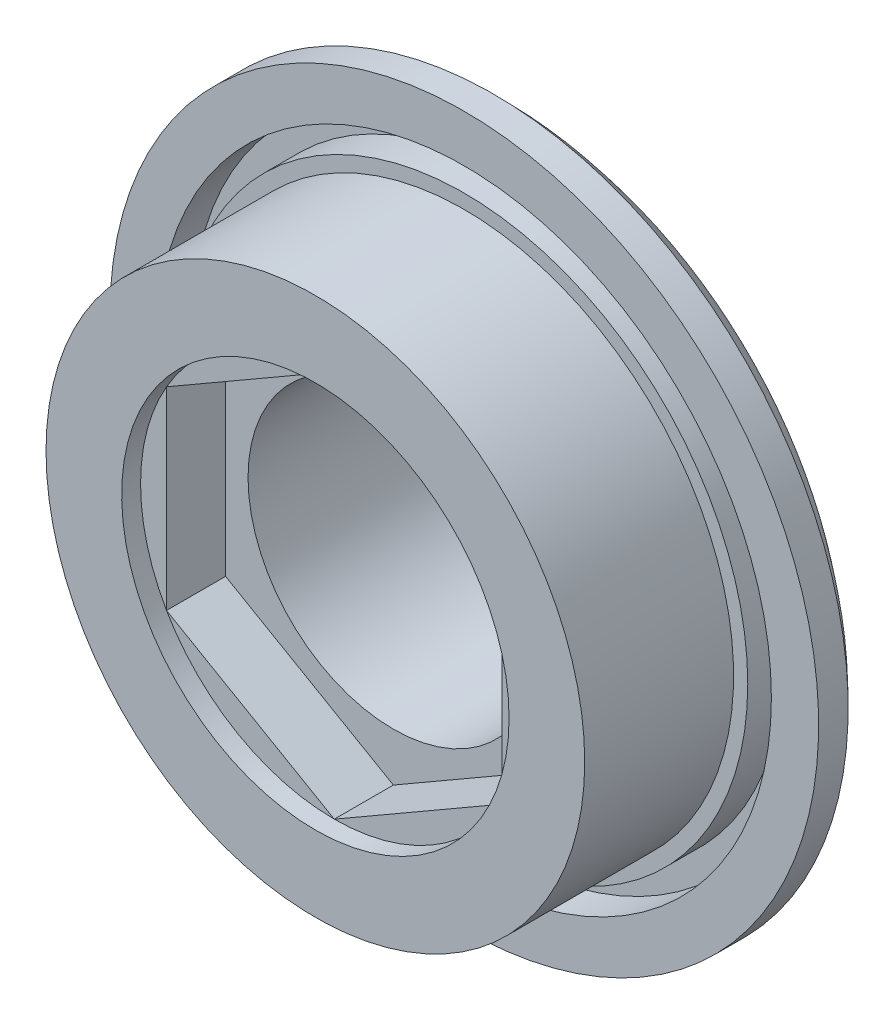
from build123d import *

# Parameters (mm, degrees)
CUT_EXTRUDE2_DEPTH  = 7
SKETCH2_R           = 13
CUT_EXTRUDE1_DEPTH  = 4.5
SKETCH5_R           = 11.4
SKETCH5_R_2         = 8.198373822
BOSS_EXTRUDE2_DEPTH = 0.8
SKETCH6_R           = 13
SKETCH6_R_2         = 12
CUT_EXTRUDE3_DEPTH  = 1.5


with BuildPart() as part:
    # Sketch1 → Revolve1 (revolve)
    with BuildSketch(Plane(origin=(0, 0, 0), x_dir=(1, 0, 0), z_dir=(0, 1, 0))):
        with BuildLine():
            Line((6.15, -14.25), (6.15, 0))
            Line((6.15, 0), (8, 0))
            ThreePointArc((8, 0), (11.807886553, -0.781598043), (15, -3))
            Line((15, -3), (15, -4.25))
            Line((15, -4.25), (11.4, -4.25))
            Line((11.4, -4.25), (11.4, -14.25))
            Line((11.4, -14.25), (6.15, -14.25))
        make_face()
    revolve(axis=Axis((0, 0, 0), (0, 0, 1)))

    # Sketch3 → Cut-Extrude2 (cut)
    with BuildSketch(Plane.XY.offset(14.25)):
        Polygon((0, -8.198373822), (7.1, -4.099186911), (7.1, 4.099186911), (0, 8.198373822), (-7.1, 4.099186911), (-7.1, -4.099186911), align=None)
    extrude(amount=-CUT_EXTRUDE2_DEPTH, mode=Mode.SUBTRACT)

    # Sketch2 → Cut-Extrude1 (cut)
    with BuildSketch(Plane.XY.offset(14.25)):
        Circle(SKETCH2_R)
    extrude(amount=-CUT_EXTRUDE1_DEPTH, mode=Mode.SUBTRACT)

    # Sketch5 → Boss-Extrude2 (add)
    with BuildSketch(Plane.XY.offset(9.75)):
        Circle(SKETCH5_R)
        Circle(SKETCH5_R_2, mode=Mode.SUBTRACT)
    extrude(amount=BOSS_EXTRUDE2_DEPTH)

    # Sketch6 → Cut-Extrude3 (cut)
    with BuildSketch(Plane.XY.offset(4.25)):
        Circle(SKETCH6_R)
        Circle(SKETCH6_R_2, mode=Mode.SUBTRACT)
    extrude(amount=-CUT_EXTRUDE3_DEPTH, mode=Mode.SUBTRACT)


solid = part.part
